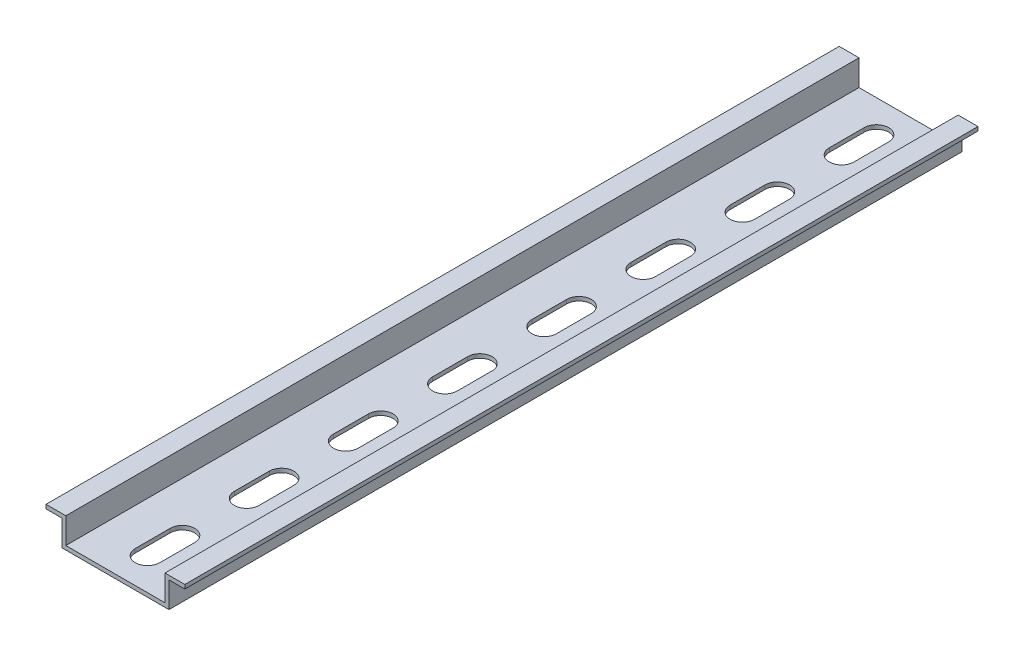
from build123d import *

# Parameters (mm, degrees)
BOSS_EXTRUDE1_DEPTH  = 200
CUT_EXTRUDE1_DEPTH   = 201.904206029
LPATTERN1_COUNT      = 8
LPATTERN1_PITCH      = 25
MIRROR2_COPY_1_DEPTH = 201.904206029
MIRROR2_COPY_2_DEPTH = 201.904206029
MIRROR2_COPY_3_DEPTH = 201.904206029
MIRROR2_COPY_4_DEPTH = 201.904206029
MIRROR2_COPY_5_DEPTH = 201.904206029
MIRROR2_COPY_6_DEPTH = 201.904206029
MIRROR2_COPY_7_DEPTH = 201.904206029


with BuildPart() as part:
    # Sketch1 → Boss-Extrude1 (new body)
    with BuildSketch(Plane.XY):
        Polygon((0, 0), (13.5, 0), (13.5, 6.5), (17.5, 6.5), (17.5, 7.5), (12.5, 7.5), (12.5, 1), (0, 1), align=None)
    boss_extrude1 = extrude(amount=BOSS_EXTRUDE1_DEPTH)

    # Sketch2 → Cut-Extrude1 (cut, through all)
    with BuildSketch(Plane(origin=(0, 0, 0), x_dir=(1, 0, 0), z_dir=(0, 1, 0))):
        with BuildLine():
            Line((3.1, -8.1), (3.1, -16.9))
            ThreePointArc((3.1, -16.9), (0, -20), (-3.1, -16.9))
            Line((-3.1, -16.9), (-3.1, -8.1))
            ThreePointArc((-3.1, -8.1), (0, -5), (3.1, -8.1))
        make_face()
    cut_extrude1 = extrude(amount=CUT_EXTRUDE1_DEPTH, mode=Mode.SUBTRACT)

    # LPattern1: Cut-Extrude1 ×8
    with Locations(*[(0, 0, i * LPATTERN1_PITCH) for i in range(1, LPATTERN1_COUNT)]):
        add(cut_extrude1, mode=Mode.SUBTRACT)

    # Mirror2: Boss-Extrude1, Cut-Extrude1 across plane
    add(boss_extrude1.mirror(Plane(origin=(0, 0, 0), x_dir=(0, 0, 1), z_dir=(1, 0, 0))))
    add(cut_extrude1.mirror(Plane(origin=(0, 0, 0), x_dir=(0, 0, 1), z_dir=(1, 0, 0))), mode=Mode.SUBTRACT)

    # Mirror2 copy 1 sketch → Mirror2 copy 1 (cut, through all)
    with BuildSketch(Plane(origin=(0, 0, 25), x_dir=(-1, 0, 0), z_dir=(0, 1, 0))):
        with BuildLine():
            Line((3.1, 8.1), (3.1, 16.9))
            ThreePointArc((3.1, 16.9), (0, 20), (-3.1, 16.9))
            Line((-3.1, 16.9), (-3.1, 8.1))
            ThreePointArc((-3.1, 8.1), (0, 5), (3.1, 8.1))
        make_face()
    extrude(amount=MIRROR2_COPY_1_DEPTH, mode=Mode.SUBTRACT)

    # Mirror2 copy 2 sketch → Mirror2 copy 2 (cut, through all)
    with BuildSketch(Plane(origin=(0, 0, 50), x_dir=(-1, 0, 0), z_dir=(0, 1, 0))):
        with BuildLine():
            Line((3.1, 8.1), (3.1, 16.9))
            ThreePointArc((3.1, 16.9), (0, 20), (-3.1, 16.9))
            Line((-3.1, 16.9), (-3.1, 8.1))
            ThreePointArc((-3.1, 8.1), (0, 5), (3.1, 8.1))
        make_face()
    extrude(amount=MIRROR2_COPY_2_DEPTH, mode=Mode.SUBTRACT)

    # Mirror2 copy 3 sketch → Mirror2 copy 3 (cut, through all)
    with BuildSketch(Plane(origin=(0, 0, 75), x_dir=(-1, 0, 0), z_dir=(0, 1, 0))):
        with BuildLine():
            Line((3.1, 8.1), (3.1, 16.9))
            ThreePointArc((3.1, 16.9), (0, 20), (-3.1, 16.9))
            Line((-3.1, 16.9), (-3.1, 8.1))
            ThreePointArc((-3.1, 8.1), (0, 5), (3.1, 8.1))
        make_face()
    extrude(amount=MIRROR2_COPY_3_DEPTH, mode=Mode.SUBTRACT)

    # Mirror2 copy 4 sketch → Mirror2 copy 4 (cut, through all)
    with BuildSketch(Plane(origin=(0, 0, 100), x_dir=(-1, 0, 0), z_dir=(0, 1, 0))):
        with BuildLine():
            Line((3.1, 8.1), (3.1, 16.9))
            ThreePointArc((3.1, 16.9), (0, 20), (-3.1, 16.9))
            Line((-3.1, 16.9), (-3.1, 8.1))
            ThreePointArc((-3.1, 8.1), (0, 5), (3.1, 8.1))
        make_face()
    extrude(amount=MIRROR2_COPY_4_DEPTH, mode=Mode.SUBTRACT)

    # Mirror2 copy 5 sketch → Mirror2 copy 5 (cut, through all)
    with BuildSketch(Plane(origin=(0, 0, 125), x_dir=(-1, 0, 0), z_dir=(0, 1, 0))):
        with BuildLine():
            Line((3.1, 8.1), (3.1, 16.9))
            ThreePointArc((3.1, 16.9), (0, 20), (-3.1, 16.9))
            Line((-3.1, 16.9), (-3.1, 8.1))
            ThreePointArc((-3.1, 8.1), (0, 5), (3.1, 8.1))
        make_face()
    extrude(amount=MIRROR2_COPY_5_DEPTH, mode=Mode.SUBTRACT)

    # Mirror2 copy 6 sketch → Mirror2 copy 6 (cut, through all)
    with BuildSketch(Plane(origin=(0, 0, 150), x_dir=(-1, 0, 0), z_dir=(0, 1, 0))):
        with BuildLine():
            Line((3.1, 8.1), (3.1, 16.9))
            ThreePointArc((3.1, 16.9), (0, 20), (-3.1, 16.9))
            Line((-3.1, 16.9), (-3.1, 8.1))
            ThreePointArc((-3.1, 8.1), (0, 5), (3.1, 8.1))
        make_face()
    extrude(amount=MIRROR2_COPY_6_DEPTH, mode=Mode.SUBTRACT)

    # Mirror2 copy 7 sketch → Mirror2 copy 7 (cut, through all)
    with BuildSketch(Plane(origin=(0, 0, 175), x_dir=(-1, 0, 0), z_dir=(0, 1, 0))):
        with BuildLine():
            Line((3.1, 8.1), (3.1, 16.9))
            ThreePointArc((3.1, 16.9), (0, 20), (-3.1, 16.9))
            Line((-3.1, 16.9), (-3.1, 8.1))
            ThreePointArc((-3.1, 8.1), (0, 5), (3.1, 8.1))
        make_face()
    extrude(amount=MIRROR2_COPY_7_DEPTH, mode=Mode.SUBTRACT)


solid = part.part
